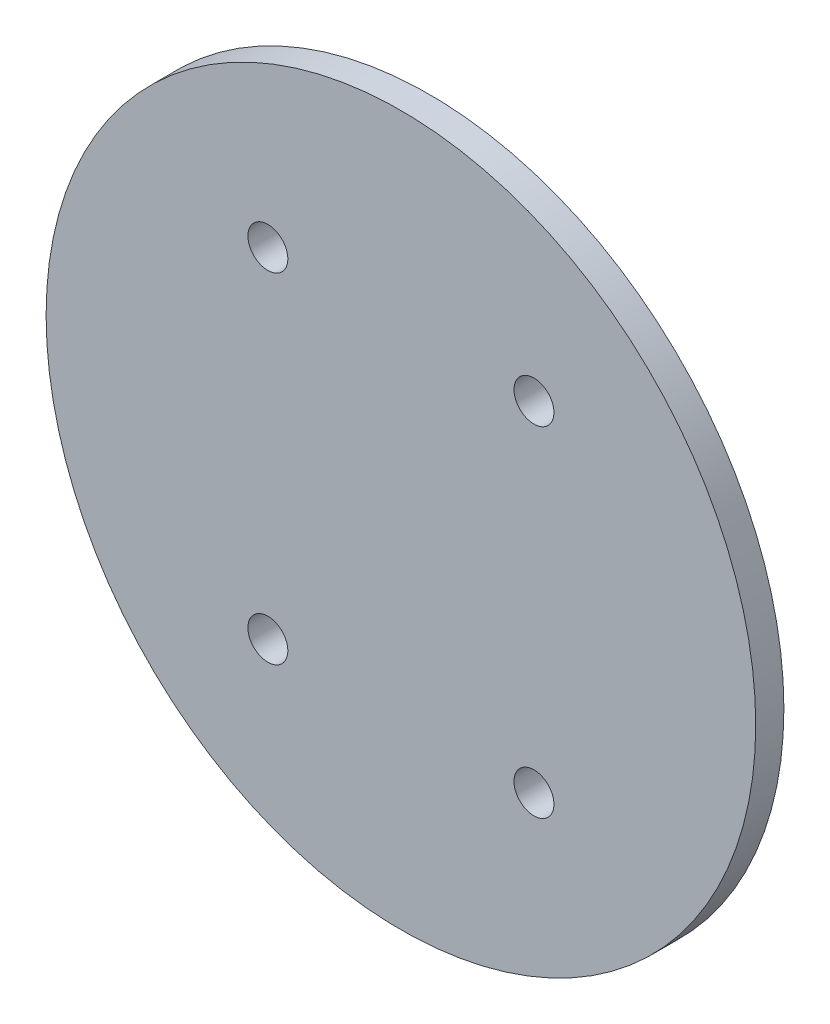
from build123d import *

# Parameters (mm, degrees)
SKETCH1_R            = 40
BOSS_EXTRUDE1_DEPTH  = 1.5875
M4_CLEARANCE_HOLE1_D = 4.5


with BuildPart() as part:
    # Sketch1 → Boss-Extrude1 (new body, symmetric)
    with BuildSketch(Plane.XY):
        Circle(SKETCH1_R)
    extrude(amount=BOSS_EXTRUDE1_DEPTH, both=True)

    # M4 Clearance Hole1 (through all)
    with Locations(Plane(origin=(0, 0, -1.5875), x_dir=(-1, 0, 0), z_dir=(0, 0, -1))):
        with Locations((15, 19.125), (-15, 19.125), (-15, -19.125), (15, -19.125)):
            Hole(M4_CLEARANCE_HOLE1_D / 2)


solid = part.part
